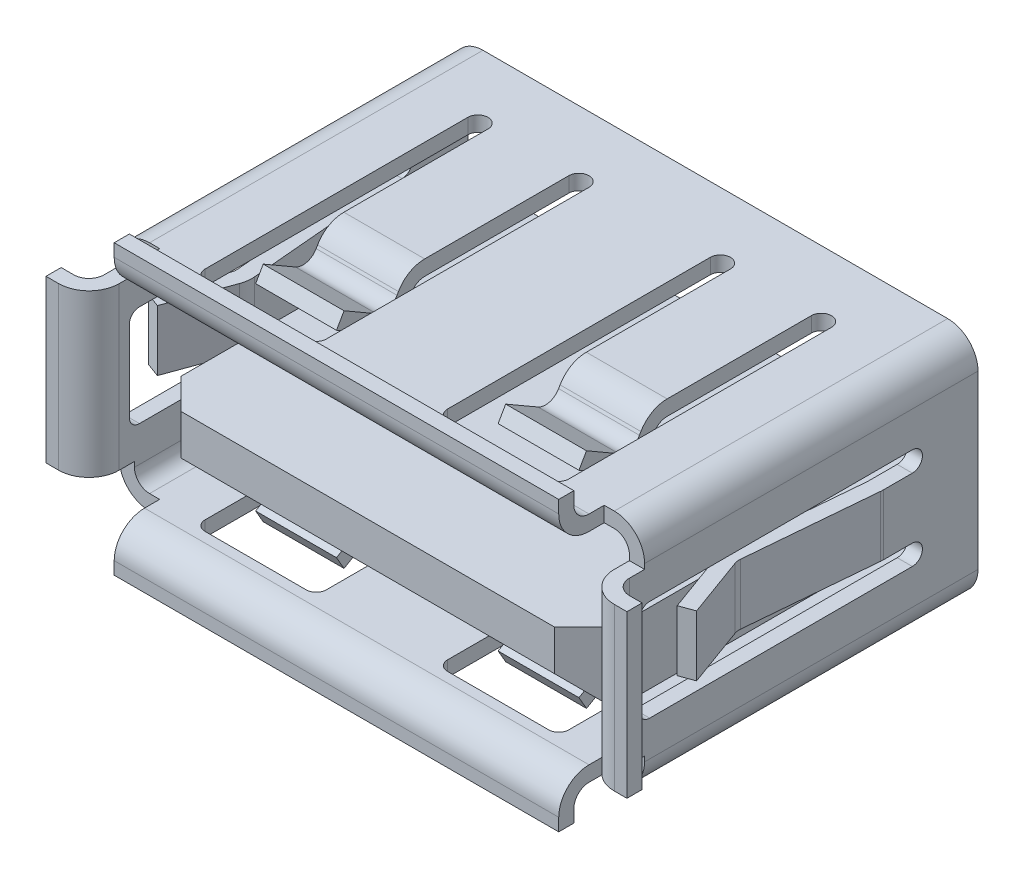
from build123d import *

# Parameters (mm, degrees)
EXTRUDE6_DEPTH     = 8.382
SKETCH11_W         = 0.381
SKETCH11_H         = 4.064
SKETCH11_W_2       = 11.176
SKETCH11_H_2       = 0.381
EXTRUDE7_DEPTH     = 0.254
EXTRUDE8_DEPTH     = 11.176
EXTRUDE9_DEPTH     = 4.064
CUT_EXTRUDE4_DEPTH = 5.842
CUT_EXTRUDE5_DEPTH = 13.462
EXTRUDE10_DEPTH    = 2.032
EXTRUDE11_DEPTH    = 2.032
EXTRUDE12_DEPTH    = 1.524
SKETCH21_W         = 10.922
SKETCH21_H         = 1.778
EXTRUDE14_DEPTH    = 8.7376
CHAMFER2_SIZE      = 0.762


with BuildPart() as part:
    # Sketch10 → Extrude6 (new body)
    with BuildSketch(Plane.XY):
        with BuildLine():
            Line((-5.842, 2.921), (5.842, 2.921))
            ThreePointArc((5.842, 2.921), (6.380815367, 2.697815367), (6.604, 2.159))
            Line((6.604, 2.159), (6.604, -2.159))
            ThreePointArc((6.604, -2.159), (6.380815367, -2.697815367), (5.842, -2.921))
            Line((5.842, -2.921), (-5.842, -2.921))
            ThreePointArc((-5.842, -2.921), (-6.380815367, -2.697815367), (-6.604, -2.159))
            Line((-6.604, -2.159), (-6.604, 2.159))
            ThreePointArc((-6.604, 2.159), (-6.380815367, 2.697815367), (-5.842, 2.921))
        make_face()
        with BuildLine():
            Line((-5.842, 2.54), (5.842, 2.54))
            ThreePointArc((5.842, 2.54), (6.111407684, 2.428407684), (6.223, 2.159))
            Line((6.223, 2.159), (6.223, -2.159))
            ThreePointArc((6.223, -2.159), (6.111407684, -2.428407684), (5.842, -2.54))
            Line((5.842, -2.54), (-5.842, -2.54))
            ThreePointArc((-5.842, -2.54), (-6.111407684, -2.428407684), (-6.223, -2.159))
            Line((-6.223, -2.159), (-6.223, 2.159))
            ThreePointArc((-6.223, 2.159), (-6.111407684, 2.428407684), (-5.842, 2.54))
        make_face(mode=Mode.SUBTRACT)
    extrude(amount=EXTRUDE6_DEPTH)

    # Sketch11 → Extrude7 (add)
    with BuildSketch(Plane.XY.offset(8.382)):
        with Locations((-6.4135, 0)):
            Rectangle(SKETCH11_W, SKETCH11_H)
        with Locations((0, -2.7305)):
            Rectangle(SKETCH11_W_2, SKETCH11_H_2)
        with Locations((0, 2.7305)):
            Rectangle(SKETCH11_W_2, SKETCH11_H_2)
        with Locations((6.4135, 0)):
            Rectangle(SKETCH11_W, SKETCH11_H)
    extrude(amount=EXTRUDE7_DEPTH)

    # Sketch12 → Extrude8 (add)
    with BuildSketch(Plane(origin=(5.588, 0, 0), x_dir=(0, 0, -1), z_dir=(1, 0, 0))):
        with BuildLine():
            Line((-9.525, 3.302), (-9.525, 3.6195))
            Line((-9.525, 3.6195), (-9.144, 3.6195))
            Line((-9.144, 3.6195), (-9.144, 3.302))
            ThreePointArc((-9.144, 3.302), (-9.032407684, 3.032592316), (-8.763, 2.921))
            Line((-8.763, 2.921), (-8.382, 2.921))
            Line((-8.382, 2.921), (-8.382, 2.54))
            Line((-8.382, 2.54), (-8.763, 2.54))
            ThreePointArc((-8.763, 2.54), (-9.301815367, 2.763184633), (-9.525, 3.302))
        make_face()
        with BuildLine():
            Line((-9.525, -3.302), (-9.525, -3.6195))
            Line((-9.525, -3.6195), (-9.144, -3.6195))
            Line((-9.144, -3.6195), (-9.144, -3.302))
            ThreePointArc((-9.144, -3.302), (-9.032407684, -3.032592316), (-8.763, -2.921))
            Line((-8.763, -2.921), (-8.382, -2.921))
            Line((-8.382, -2.921), (-8.382, -2.54))
            Line((-8.382, -2.54), (-8.763, -2.54))
            ThreePointArc((-8.763, -2.54), (-9.301815367, -2.763184633), (-9.525, -3.302))
        make_face()
    extrude(amount=-EXTRUDE8_DEPTH)

    # Sketch13 → Extrude9 (add)
    with BuildSketch(Plane(origin=(0, 2.032, 0), x_dir=(-1, 0, 0), z_dir=(0, 1, 0))):
        with BuildLine():
            Line((-6.985, 9.144), (-7.3025, 9.144))
            Line((-7.3025, 9.144), (-7.3025, 9.525))
            Line((-7.3025, 9.525), (-6.985, 9.525))
            ThreePointArc((-6.985, 9.525), (-6.446184633, 9.301815367), (-6.223, 8.763))
            Line((-6.223, 8.763), (-6.223, 8.382))
            Line((-6.223, 8.382), (-6.604, 8.382))
            Line((-6.604, 8.382), (-6.604, 8.763))
            ThreePointArc((-6.604, 8.763), (-6.715592316, 9.032407684), (-6.985, 9.144))
        make_face()
        with BuildLine():
            Line((6.985, 9.144), (7.3025, 9.144))
            Line((7.3025, 9.144), (7.3025, 9.525))
            Line((7.3025, 9.525), (6.985, 9.525))
            ThreePointArc((6.985, 9.525), (6.446184633, 9.301815367), (6.223, 8.763))
            Line((6.223, 8.763), (6.223, 8.382))
            Line((6.223, 8.382), (6.604, 8.382))
            Line((6.604, 8.382), (6.604, 8.763))
            ThreePointArc((6.604, 8.763), (6.715592316, 9.032407684), (6.985, 9.144))
        make_face()
    extrude(amount=-EXTRUDE9_DEPTH)

    # Sketch14 → Cut-Extrude4 (cut)
    with BuildSketch(Plane(origin=(0, 2.921, 0), x_dir=(-1, 0, 0), z_dir=(0, 1, 0))):
        with BuildLine():
            Line((-2.032, 1.651), (-2.032, 2.159))
            Line((-2.032, 2.159), (-4.064, 2.159))
            Line((-4.064, 2.159), (-4.064, 1.651))
            ThreePointArc((-4.064, 1.651), (-4.318, 1.397), (-4.572, 1.651))
            Line((-4.572, 1.651), (-4.572, 8.255))
            ThreePointArc((-4.572, 8.255), (-4.497605122, 8.434605122), (-4.318, 8.509))
            Line((-4.318, 8.509), (-1.778, 8.509))
            ThreePointArc((-1.778, 8.509), (-1.598394878, 8.434605122), (-1.524, 8.255))
            Line((-1.524, 8.255), (-1.524, 1.651))
            ThreePointArc((-1.524, 1.651), (-1.778, 1.397), (-2.032, 1.651))
        make_face()
        with BuildLine():
            Line((4.572, 1.651), (4.572, 8.255))
            ThreePointArc((4.572, 8.255), (4.497605122, 8.434605122), (4.318, 8.509))
            Line((4.318, 8.509), (1.778, 8.509))
            ThreePointArc((1.778, 8.509), (1.598394878, 8.434605122), (1.524, 8.255))
            Line((1.524, 8.255), (1.524, 1.651))
            ThreePointArc((1.524, 1.651), (1.778, 1.397), (2.032, 1.651))
            Line((2.032, 1.651), (2.032, 2.159))
            Line((2.032, 2.159), (4.064, 2.159))
            Line((4.064, 2.159), (4.064, 1.651))
            ThreePointArc((4.064, 1.651), (4.318, 1.397), (4.572, 1.651))
        make_face()
    extrude(amount=-CUT_EXTRUDE4_DEPTH, mode=Mode.SUBTRACT)

    # Sketch15 → Cut-Extrude5 (cut)
    with BuildSketch(Plane(origin=(6.604, 0, 0), x_dir=(0, 0, -1), z_dir=(1, 0, 0))):
        with BuildLine():
            Line((-8.255, 1.27), (-1.651, 1.27))
            ThreePointArc((-1.651, 1.27), (-1.397, 1.016), (-1.651, 0.762))
            Line((-1.651, 0.762), (-1.905, 0.762))
            Line((-1.905, 0.762), (-1.905, -0.762))
            Line((-1.905, -0.762), (-1.651, -0.762))
            ThreePointArc((-1.651, -0.762), (-1.397, -1.016), (-1.651, -1.27))
            Line((-1.651, -1.27), (-8.255, -1.27))
            ThreePointArc((-8.255, -1.27), (-8.434605122, -1.195605122), (-8.509, -1.016))
            Line((-8.509, -1.016), (-8.509, 1.016))
            ThreePointArc((-8.509, 1.016), (-8.434605122, 1.195605122), (-8.255, 1.27))
        make_face()
    extrude(amount=-CUT_EXTRUDE5_DEPTH, mode=Mode.SUBTRACT)

    # Sketch17 → Extrude10 (add)
    with BuildSketch(Plane(origin=(4.064, 0, 0), x_dir=(0, 0, -1), z_dir=(1, 0, 0))):
        with BuildLine():
            Line((-5.934970453, 2.54), (-5.971632195, 2.4765))
            ThreePointArc((-5.971632195, 2.4765), (-6.202977817, 2.29898226), (-6.492087873, 2.337044321))
            Line((-6.492087873, 2.337044321), (-7.3025, 2.804935981))
            Line((-7.3025, 2.804935981), (-7.493, 2.474980302))
            Line((-7.493, 2.474980302), (-6.682587873, 2.007088642))
            ThreePointArc((-6.682587873, 2.007088642), (-6.104367761, 1.93096452), (-5.641676516, 2.286))
            Line((-5.641676516, 2.286), (-5.605014774, 2.3495))
            ThreePointArc((-5.605014774, 2.3495), (-5.465559095, 2.488955679), (-5.275059095, 2.54))
            Line((-5.275059095, 2.54), (-1.651, 2.54))
            Line((-1.651, 2.54), (-1.651, 2.921))
            Line((-1.651, 2.921), (-5.275059095, 2.921))
            ThreePointArc((-5.275059095, 2.921), (-5.656059095, 2.818911358), (-5.934970453, 2.54))
        make_face()
        with BuildLine():
            Line((-5.641676516, -2.286), (-5.605014774, -2.3495))
            ThreePointArc((-5.605014774, -2.3495), (-5.465559095, -2.488955679), (-5.275059095, -2.54))
            Line((-5.275059095, -2.54), (-1.651, -2.54))
            Line((-1.651, -2.54), (-1.651, -2.921))
            Line((-1.651, -2.921), (-5.275059095, -2.921))
            ThreePointArc((-5.275059095, -2.921), (-5.656059095, -2.818911358), (-5.934970453, -2.54))
            Line((-5.934970453, -2.54), (-5.971632195, -2.4765))
            ThreePointArc((-5.971632195, -2.4765), (-6.202977817, -2.29898226), (-6.492087873, -2.337044321))
            Line((-6.492087873, -2.337044321), (-7.3025, -2.804935981))
            Line((-7.3025, -2.804935981), (-7.493, -2.474980302))
            Line((-7.493, -2.474980302), (-6.682587873, -2.007088642))
            ThreePointArc((-6.682587873, -2.007088642), (-6.104367761, -1.93096452), (-5.641676516, -2.286))
        make_face()
    extrude(amount=-EXTRUDE10_DEPTH)

    # Sketch18 → Extrude11 (add)
    with BuildSketch(Plane(origin=(-2.032, 0, 0), x_dir=(0, 0, -1), z_dir=(1, 0, 0))):
        with BuildLine():
            Line((-5.934970453, 2.54), (-5.971632195, 2.4765))
            ThreePointArc((-5.971632195, 2.4765), (-6.202977817, 2.29898226), (-6.492087873, 2.337044321))
            Line((-6.492087873, 2.337044321), (-7.3025, 2.804935981))
            Line((-7.3025, 2.804935981), (-7.493, 2.474980302))
            Line((-7.493, 2.474980302), (-6.682587873, 2.007088642))
            ThreePointArc((-6.682587873, 2.007088642), (-6.104367761, 1.93096452), (-5.641676516, 2.286))
            Line((-5.641676516, 2.286), (-5.605014774, 2.3495))
            ThreePointArc((-5.605014774, 2.3495), (-5.465559095, 2.488955679), (-5.275059095, 2.54))
            Line((-5.275059095, 2.54), (-1.651, 2.54))
            Line((-1.651, 2.54), (-1.651, 2.921))
            Line((-1.651, 2.921), (-5.275059095, 2.921))
            ThreePointArc((-5.275059095, 2.921), (-5.656059095, 2.818911358), (-5.934970453, 2.54))
        make_face()
        with BuildLine():
            Line((-5.605014774, -2.3495), (-5.641676516, -2.286))
            ThreePointArc((-5.641676516, -2.286), (-6.104367761, -1.93096452), (-6.682587873, -2.007088642))
            Line((-6.682587873, -2.007088642), (-7.493, -2.474980302))
            Line((-7.493, -2.474980302), (-7.3025, -2.804935981))
            Line((-7.3025, -2.804935981), (-6.492087873, -2.337044321))
            ThreePointArc((-6.492087873, -2.337044321), (-6.202977817, -2.29898226), (-5.971632195, -2.4765))
            Line((-5.971632195, -2.4765), (-5.934970453, -2.54))
            ThreePointArc((-5.934970453, -2.54), (-5.656059095, -2.818911358), (-5.275059095, -2.921))
            Line((-5.275059095, -2.921), (-1.651, -2.921))
            Line((-1.651, -2.921), (-1.651, -2.54))
            Line((-1.651, -2.54), (-5.275059095, -2.54))
            ThreePointArc((-5.275059095, -2.54), (-5.465559095, -2.488955679), (-5.605014774, -2.3495))
        make_face()
    extrude(amount=-EXTRUDE11_DEPTH)

    # Sketch20 → Extrude12 (add)
    with BuildSketch(Plane(origin=(0, 0.762, 0), x_dir=(-1, 0, 0), z_dir=(0, 1, 0))):
        with BuildLine():
            Line((-6.60110036, 2.446143037), (-6.318017611, 5.681793662))
            ThreePointArc((-6.318017611, 5.681793662), (-6.319827299, 5.764730479), (-6.339544903, 5.845309675))
            Line((-6.339544903, 5.845309675), (-6.891826294, 7.362690325))
            Line((-6.891826294, 7.362690325), (-6.533803405, 7.493))
            Line((-6.533803405, 7.493), (-5.981522014, 5.975619349))
            ThreePointArc((-5.981522014, 5.975619349), (-5.942086807, 5.814460958), (-5.938467431, 5.648587324))
            Line((-5.938467431, 5.648587324), (-6.223, 2.396365181))
            Line((-6.223, 2.396365181), (-6.223, 1.651))
            Line((-6.223, 1.651), (-6.604, 1.651))
            Line((-6.604, 1.651), (-6.604, 2.379730362))
            ThreePointArc((-6.604, 2.379730362), (-6.603274745, 2.412968335), (-6.60110036, 2.446143037))
        make_face()
        with BuildLine():
            Line((6.60110036, 2.446143037), (6.318017611, 5.681793662))
            ThreePointArc((6.318017611, 5.681793662), (6.319827299, 5.764730479), (6.339544903, 5.845309675))
            Line((6.339544903, 5.845309675), (6.891826294, 7.362690325))
            Line((6.891826294, 7.362690325), (6.533803405, 7.493))
            Line((6.533803405, 7.493), (5.981522014, 5.975619349))
            ThreePointArc((5.981522014, 5.975619349), (5.942086807, 5.814460958), (5.938467431, 5.648587324))
            Line((5.938467431, 5.648587324), (6.223, 2.396365181))
            Line((6.223, 2.396365181), (6.223, 1.651))
            Line((6.223, 1.651), (6.604, 1.651))
            Line((6.604, 1.651), (6.604, 2.379730362))
            ThreePointArc((6.604, 2.379730362), (6.603274745, 2.412968335), (6.60110036, 2.446143037))
        make_face()
    extrude(amount=-EXTRUDE12_DEPTH)


with BuildPart() as body_2:
    # Sketch21 → Extrude14 (new body)
    with BuildSketch(Plane.XY):
        with Locations((0, -0.889)):
            Rectangle(SKETCH21_W, SKETCH21_H)
    extrude(amount=EXTRUDE14_DEPTH)

    # Chamfer2
    chamfer2_edges = [body_2.edges().sort_by_distance(p)[0] for p in [
        (5.461, -0.889, 8.7376),
        (-5.461, -0.889, 8.7376),
        (0, -1.778, 8.7376),
    ]]
    chamfer(chamfer2_edges, length=CHAMFER2_SIZE)


solid = Compound([part.part, body_2.part])
